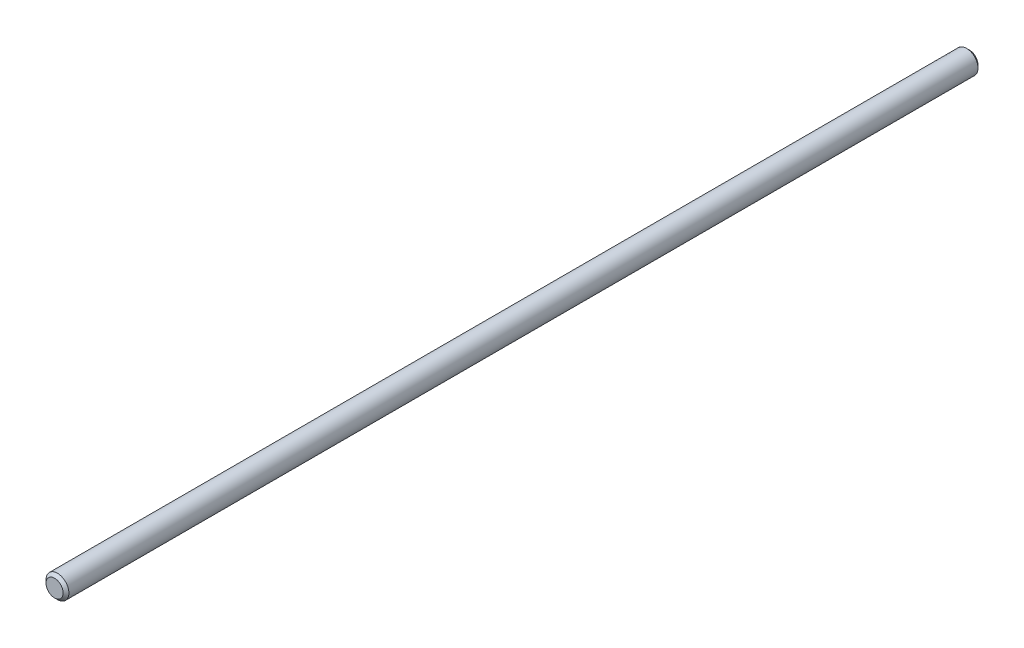
from build123d import *

# Parameters (mm, degrees)
SKETCH1_R           = 2
BOSS_EXTRUDE1_DEPTH = 80
CHAMFER1_SIZE       = 0.5


with BuildPart() as part:
    # Sketch1 → Boss-Extrude1 (new body, symmetric)
    with BuildSketch(Plane.XY):
        Circle(SKETCH1_R)
    extrude(amount=BOSS_EXTRUDE1_DEPTH, both=True)

    # Chamfer1
    chamfer1_edges = [part.edges().sort_by_distance(p)[0] for p in [
        (-2, 0, -80),
        (-2, 0, 80),
    ]]
    chamfer(chamfer1_edges, length=CHAMFER1_SIZE)


solid = part.part
